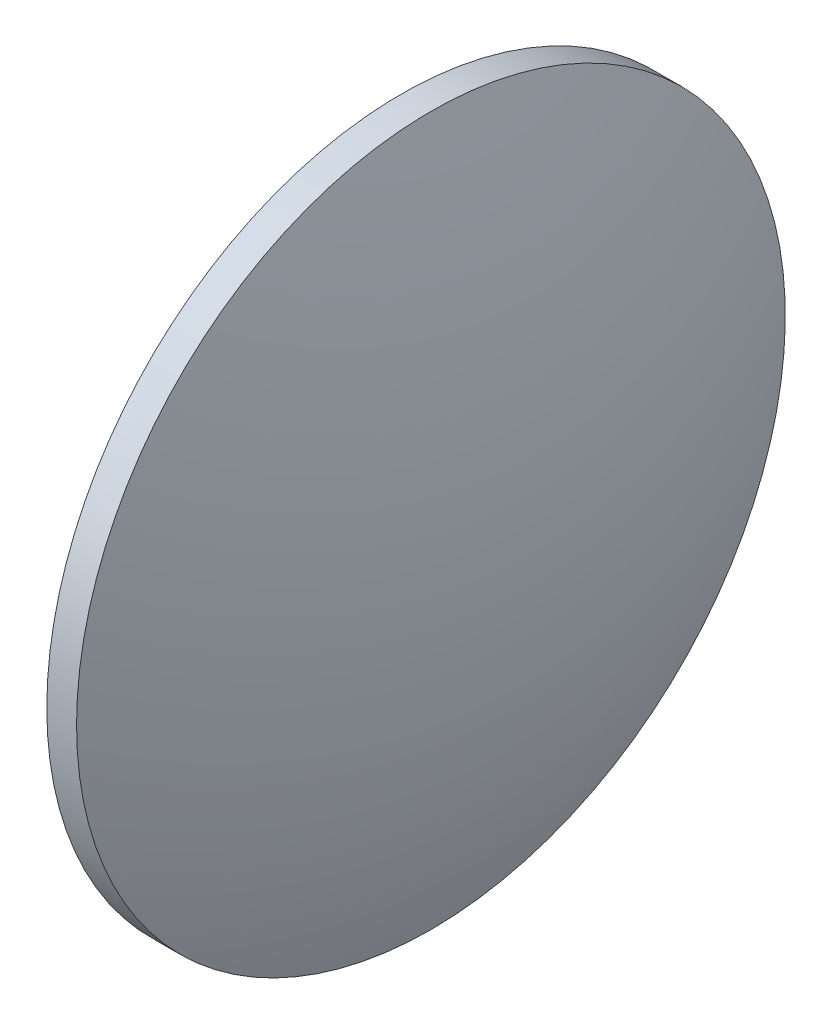
from build123d import *


with BuildPart() as part:
    # 草图1 → 旋转1 (revolve)
    with BuildSketch(Plane.XY, mode=Mode.PRIVATE) as revolve_1_sk:
        with BuildLine():
            Line((113.313781958, 65.02094538), (113.313781958, 87.52094538))
            Line((113.313781958, 87.52094538), (115.203781958, 87.52094538))
            ThreePointArc((115.203781958, 87.52094538), (118.352227619, 76.466185657), (119.413781958, 65.02094538))
            Line((119.413781958, 65.02094538), (113.313781958, 65.02094538))
        make_face()
    revolve(revolve_1_sk.sketch.rotate(Axis((108.66557433, 65.02094538, 0), (1, 0, 0)), 180), axis=Axis((108.66557433, 65.02094538, 0), (1, 0, 0)))  # turned: the seam where the file's is


solid = part.part
